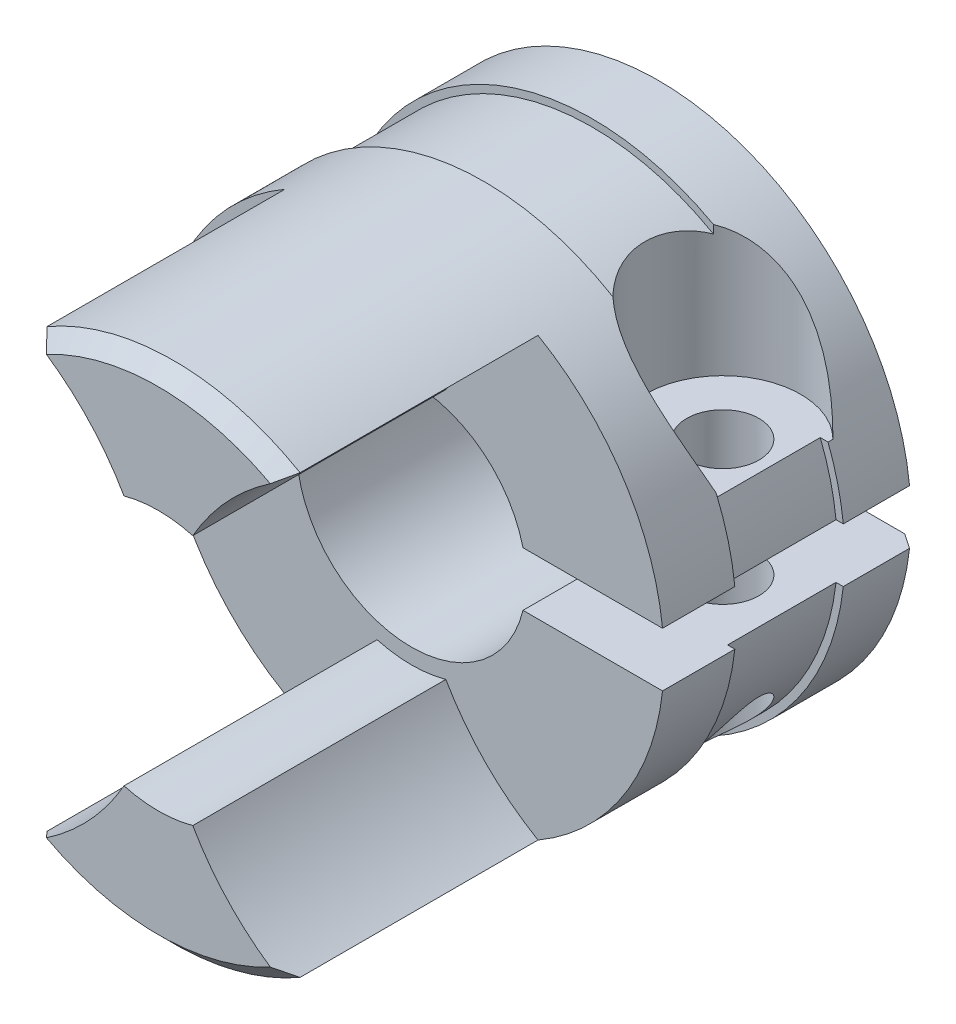
from build123d import *
from OCP.BRepFilletAPI import BRepFilletAPI_MakeChamfer

# Parameters (mm, degrees)
BOSS_EXTRUDE1_START     = -3.937
SKETCH1_R               = 6.985
BOSS_EXTRUDE1_DEPTH     = 7.112
CUT_EXTRUDE10_START     = -2
SKETCH25_R              = 6.985
SKETCH25_R_2            = 6.785
CUT_EXTRUDE10_DEPTH     = 3
BOSS_EXTRUDE2_DEPTH     = 7
CIRPATTERN1_COUNT       = 2
CUT_EXTRUDE5_DEPTH      = 15.820959854
CUT_EXTRUDE5_DEPTH_BACK = 15.820959854
SKETCH15_R              = 3.175
CHAMFER1_SIZE           = 0.2794
CHAMFER1_SIZE2          = 0.414227535
SKETCH19_R              = 2.154
CUT_EXTRUDE6_DEPTH      = 17.15041344
SKETCH23_W              = 6.985
SKETCH23_H              = 1.5
CUT_EXTRUDE9_DEPTH      = 15.820959948
CHAMFER6_SIZE           = 0.4191


with BuildPart() as part:
    # Sketch1 → Boss-Extrude1 (new body)
    with BuildSketch(Plane.XY.offset(BOSS_EXTRUDE1_START)):
        Circle(SKETCH1_R)
    extrude(amount=-BOSS_EXTRUDE1_DEPTH)

    # Sketch25 → Cut-Extrude10 (cut)
    with BuildSketch(Plane.XY.offset(-3.937).offset(CUT_EXTRUDE10_START)):
        Circle(SKETCH25_R)
        Circle(SKETCH25_R_2, mode=Mode.SUBTRACT)
    extrude(amount=-CUT_EXTRUDE10_DEPTH, mode=Mode.SUBTRACT)

    # Sketch2 → Boss-Extrude2 (add)
    with BuildSketch(Plane.XY.offset(-3.937)):
        with BuildLine():
            ThreePointArc((-3.5, -6.044851115), (0, -6.985), (3.5, -6.044851115))
            ThreePointArc((3.5, -6.044851115), (2.056519165, -4.92606064), (0.951562077, -3.471963366))
            ThreePointArc((0.951562077, -3.471963366), (0, -3.6), (-0.951562077, -3.471963366))
            ThreePointArc((-0.951562077, -3.471963366), (-2.056519165, -4.92606064), (-3.5, -6.044851115))
        make_face()
    boss_extrude2 = extrude(amount=BOSS_EXTRUDE2_DEPTH)

    # CirPattern1: Boss-Extrude2 ×2 about axis
    cirpattern1_axis = Axis((0, 0, 0), (0, 0, 1))
    for i in range(1, CIRPATTERN1_COUNT):
        add(boss_extrude2.rotate(cirpattern1_axis, i * 360 / CIRPATTERN1_COUNT))

    # Sketch15 → Cut-Extrude5 (cut, two sides: drawn at the far end of the back side and taken through both)
    with BuildSketch(Plane.XY.offset(-CUT_EXTRUDE5_DEPTH_BACK)):
        Circle(SKETCH15_R)
    extrude(amount=CUT_EXTRUDE5_DEPTH + CUT_EXTRUDE5_DEPTH_BACK, mode=Mode.SUBTRACT)

    # Chamfer1: one chamfer whose edges measure the first distance from different faces: ONE call of the kernel's chamfer builder (chamfer() names one face for all edges)
    chamfer1_edges_1 = [part.edges().sort_by_distance(p)[0] for p in [
        (-3.175, 0, -11.049),
    ]]
    chamfer1_side_1 = [part.faces().sort_by_distance(p)[0] for p in [
        (-3.175, 0, -7.493),
    ]]
    chamfer1_edges_2 = [part.edges().sort_by_distance(p)[0] for p in [
        (-6.985, 0, -11.049),
    ]]
    chamfer1_side_2 = [part.faces().sort_by_distance(p)[0] for p in [
        (-6.985, 0, -9.993),
    ]]
    chamfer1 = BRepFilletAPI_MakeChamfer(part.part.solid().wrapped)
    for e in chamfer1_edges_1:
        chamfer1.Add(CHAMFER1_SIZE, CHAMFER1_SIZE2, e.wrapped, chamfer1_side_1[0].wrapped)  # the first distance lies on this face
    for e in chamfer1_edges_2:
        chamfer1.Add(CHAMFER1_SIZE, CHAMFER1_SIZE2, e.wrapped, chamfer1_side_2[0].wrapped)  # the first distance lies on this face
    add(Compound.cast(chamfer1.Shape()), mode=Mode.REPLACE)

    # Sketch17 → Cut-Revolve1 (revolve, cut)
    with BuildSketch(Plane(origin=(0, 0, -7.549), x_dir=(-1, 0, 0), z_dir=(0, 0, -1)), mode=Mode.PRIVATE) as cut_revolve1_sk:
        Polygon((-6, 2.5), (-6, -7.201139233), (-5, -7.201139233), (-5, 4.499600677), (-5, 8.2375), (-6.9, 8.2375), (-6.9, 4.499600677), (-6.9, 2.5), align=None)
    revolve(cut_revolve1_sk.sketch.rotate(Axis((5, 4.499600677, -7.549), (0, -1, 0)), 180), axis=Axis((5, 4.499600677, -7.549), (0, -1, 0)), mode=Mode.SUBTRACT)

    # Sketch19 → Cut-Extrude6 (cut, through all)
    with BuildSketch(Plane(origin=(0, 2.5, 0), x_dir=(1, 0, 0), z_dir=(0, 1, 0))):
        with Locations((5, 7.549)):
            Circle(SKETCH19_R)
    extrude(amount=CUT_EXTRUDE6_DEPTH, mode=Mode.SUBTRACT)

    # Sketch23 → Cut-Extrude9 (cut, through all)
    with BuildSketch(Plane.XY):
        with Locations((3.4925, 0)):
            Rectangle(SKETCH23_W, SKETCH23_H)
    extrude(amount=-CUT_EXTRUDE9_DEPTH, mode=Mode.SUBTRACT)

    # Chamfer6
    chamfer6_edges = [part.edges().sort_by_distance(p)[0] for p in [
        (0, -6.985, 3.063),
        (0, 6.985, 3.063),
    ]]
    chamfer(chamfer6_edges, length=CHAMFER6_SIZE)


solid = part.part
